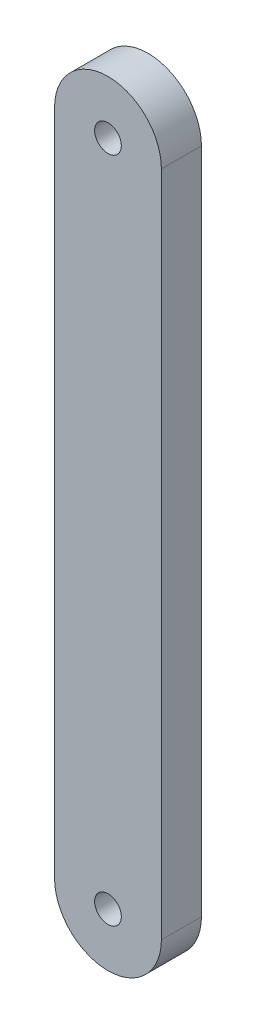
from build123d import *

# Parameters (mm, degrees)
MODEL_R             = 1
BOSS_EXTRUDE1_DEPTH = 3


with BuildPart() as part:
    # Model → Boss-Extrude1 (new body)
    with BuildSketch(Plane.XY):
        with BuildLine():
            Line((34.746875971, 62.545608907), (34.746875971, 12.545608907))
            ThreePointArc((34.746875971, 12.545608907), (38.746875971, 8.545608907), (42.746875971, 12.545608907))
            Line((42.746875971, 12.545608907), (42.746875971, 62.545608907))
            ThreePointArc((42.746875971, 62.545608907), (38.746875971, 66.545608907), (34.746875971, 62.545608907))
        make_face()
        with Locations((38.746875971, 12.545608907)):
            Circle(MODEL_R, mode=Mode.SUBTRACT)
        with Locations((38.746875971, 62.545608907)):
            Circle(MODEL_R, mode=Mode.SUBTRACT)
    extrude(amount=BOSS_EXTRUDE1_DEPTH)


solid = part.part
